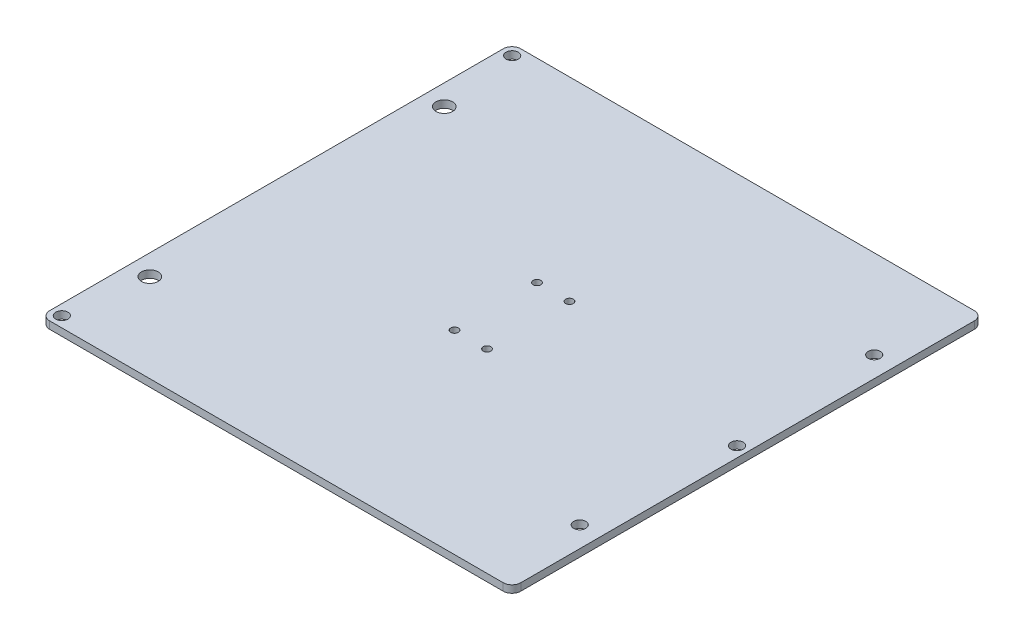
from build123d import *

# Parameters (mm, degrees)
SKETCH1_W               = 203.2
SKETCH1_H               = 203.2
BOSS_EXTRUDE1_DEPTH     = 3.175
WHEEL_HOLES_REACH       = 5.175
SKETCH2_R               = 3.6
SKETCH2_R_2             = 2.625
BUILD_PLATE_HOLES_REACH = 5.175
SKETCH3_R               = 2.625
FILLET1_R               = 3.81
BELT_CLAMP_HOLES_REACH  = 5.175
SKETCH4_R               = 1.65


with BuildPart() as part:
    # Sketch1 → Boss-Extrude1 (new body)
    with BuildSketch(Plane(origin=(0, 0, 0), x_dir=(1, 0, 0), z_dir=(0, 1, 0))):
        with Locations((101.6, 101.6)):
            Rectangle(SKETCH1_W, SKETCH1_H)
    extrude(amount=BOSS_EXTRUDE1_DEPTH)

    # Sketch2 → wheel holes (cut, up to next)
    with BuildSketch(Plane(origin=(0, 3.175, 0), x_dir=(1, 0, 0), z_dir=(0, 1, 0)), mode=Mode.PRIVATE) as wheel_holes_sk1:
        with Locations((8.90143, 38.1)):
            Circle(SKETCH2_R)
    wheel_holes_tool1 = extrude(wheel_holes_sk1.sketch, amount=-WHEEL_HOLES_REACH, mode=Mode.PRIVATE) & part.part
    add(wheel_holes_tool1.solids().sort_by_distance((8.90143, 3.175, -38.1))[0], mode=Mode.SUBTRACT)
    # Sketch2 → wheel holes (cut, up to next)
    with BuildSketch(Plane(origin=(0, 3.175, 0), x_dir=(1, 0, 0), z_dir=(0, 1, 0)), mode=Mode.PRIVATE) as wheel_holes_sk2:
        with Locations((8.90143, 165.1)):
            Circle(SKETCH2_R)
    wheel_holes_tool2 = extrude(wheel_holes_sk2.sketch, amount=-WHEEL_HOLES_REACH, mode=Mode.PRIVATE) & part.part
    add(wheel_holes_tool2.solids().sort_by_distance((8.90143, 3.175, -165.1))[0], mode=Mode.SUBTRACT)
    # Sketch2 → wheel holes (cut, up to next)
    with BuildSketch(Plane(origin=(0, 3.175, 0), x_dir=(1, 0, 0), z_dir=(0, 1, 0)), mode=Mode.PRIVATE) as wheel_holes_sk3:
        with Locations((194.29857, 38.1)):
            Circle(SKETCH2_R_2)
    wheel_holes_tool3 = extrude(wheel_holes_sk3.sketch, amount=-WHEEL_HOLES_REACH, mode=Mode.PRIVATE) & part.part
    add(wheel_holes_tool3.solids().sort_by_distance((194.29857, 3.175, -38.1))[0], mode=Mode.SUBTRACT)
    # Sketch2 → wheel holes (cut, up to next)
    with BuildSketch(Plane(origin=(0, 3.175, 0), x_dir=(1, 0, 0), z_dir=(0, 1, 0)), mode=Mode.PRIVATE) as wheel_holes_sk4:
        with Locations((194.29857, 165.1)):
            Circle(SKETCH2_R_2)
    wheel_holes_tool4 = extrude(wheel_holes_sk4.sketch, amount=-WHEEL_HOLES_REACH, mode=Mode.PRIVATE) & part.part
    add(wheel_holes_tool4.solids().sort_by_distance((194.29857, 3.175, -165.1))[0], mode=Mode.SUBTRACT)

    # Sketch3 → build plate holes (cut, up to next)
    with BuildSketch(Plane.XZ, mode=Mode.PRIVATE) as build_plate_holes_sk1:
        with Locations((4.50088, -4.572)):
            Circle(SKETCH3_R)
    build_plate_holes_tool1 = extrude(build_plate_holes_sk1.sketch, amount=-BUILD_PLATE_HOLES_REACH, mode=Mode.PRIVATE) & part.part
    add(build_plate_holes_tool1.solids().sort_by_distance((4.50088, 0, -4.572))[0], mode=Mode.SUBTRACT)
    # Sketch3 → build plate holes (cut, up to next)
    with BuildSketch(Plane.XZ, mode=Mode.PRIVATE) as build_plate_holes_sk2:
        with Locations((4.50088, -198.77278)):
            Circle(SKETCH3_R)
    build_plate_holes_tool2 = extrude(build_plate_holes_sk2.sketch, amount=-BUILD_PLATE_HOLES_REACH, mode=Mode.PRIVATE) & part.part
    add(build_plate_holes_tool2.solids().sort_by_distance((4.50088, 0, -198.77278))[0], mode=Mode.SUBTRACT)
    # Sketch3 → build plate holes (cut, up to next)
    with BuildSketch(Plane.XZ, mode=Mode.PRIVATE) as build_plate_holes_sk3:
        with Locations((198.6499964, -101.6)):
            Circle(SKETCH3_R)
    build_plate_holes_tool3 = extrude(build_plate_holes_sk3.sketch, amount=-BUILD_PLATE_HOLES_REACH, mode=Mode.PRIVATE) & part.part
    add(build_plate_holes_tool3.solids().sort_by_distance((198.649996, 0, -101.6))[0], mode=Mode.SUBTRACT)

    # Fillet1
    fillet1_edges = [part.edges().sort_by_distance(p)[0] for p in [
        (0, 1.5875, -203.2),
        (203.2, 1.5875, -203.2),
        (203.2, 1.5875, 0),
        (0, 1.5875, 0),
    ]]
    fillet(fillet1_edges, radius=FILLET1_R)

    # Sketch4 → belt clamp holes (cut, up to next)
    with BuildSketch(Plane(origin=(0, 3.175, 0), x_dir=(1, 0, 0), z_dir=(0, 1, 0)), mode=Mode.PRIVATE) as belt_clamp_holes_sk1:
        with Locations((94.6, 119.38)):
            Circle(SKETCH4_R)
    belt_clamp_holes_tool1 = extrude(belt_clamp_holes_sk1.sketch, amount=-BELT_CLAMP_HOLES_REACH, mode=Mode.PRIVATE) & part.part
    add(belt_clamp_holes_tool1.solids().sort_by_distance((94.6, 3.175, -119.38))[0], mode=Mode.SUBTRACT)
    # Sketch4 → belt clamp holes (cut, up to next)
    with BuildSketch(Plane(origin=(0, 3.175, 0), x_dir=(1, 0, 0), z_dir=(0, 1, 0)), mode=Mode.PRIVATE) as belt_clamp_holes_sk2:
        with Locations((108.6, 119.38)):
            Circle(SKETCH4_R)
    belt_clamp_holes_tool2 = extrude(belt_clamp_holes_sk2.sketch, amount=-BELT_CLAMP_HOLES_REACH, mode=Mode.PRIVATE) & part.part
    add(belt_clamp_holes_tool2.solids().sort_by_distance((108.6, 3.175, -119.38))[0], mode=Mode.SUBTRACT)
    # Sketch4 → belt clamp holes (cut, up to next)
    with BuildSketch(Plane(origin=(0, 3.175, 0), x_dir=(1, 0, 0), z_dir=(0, 1, 0)), mode=Mode.PRIVATE) as belt_clamp_holes_sk3:
        with Locations((108.6, 83.82)):
            Circle(SKETCH4_R)
    belt_clamp_holes_tool3 = extrude(belt_clamp_holes_sk3.sketch, amount=-BELT_CLAMP_HOLES_REACH, mode=Mode.PRIVATE) & part.part
    add(belt_clamp_holes_tool3.solids().sort_by_distance((108.6, 3.175, -83.82))[0], mode=Mode.SUBTRACT)
    # Sketch4 → belt clamp holes (cut, up to next)
    with BuildSketch(Plane(origin=(0, 3.175, 0), x_dir=(1, 0, 0), z_dir=(0, 1, 0)), mode=Mode.PRIVATE) as belt_clamp_holes_sk4:
        with Locations((94.6, 83.82)):
            Circle(SKETCH4_R)
    belt_clamp_holes_tool4 = extrude(belt_clamp_holes_sk4.sketch, amount=-BELT_CLAMP_HOLES_REACH, mode=Mode.PRIVATE) & part.part
    add(belt_clamp_holes_tool4.solids().sort_by_distance((94.6, 3.175, -83.82))[0], mode=Mode.SUBTRACT)


solid = part.part
